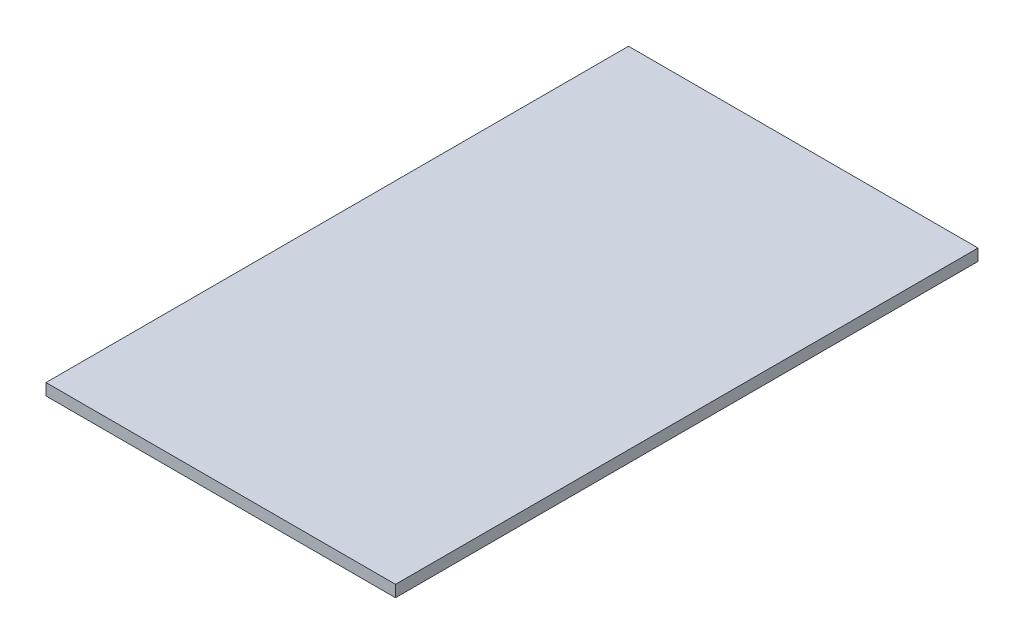
from build123d import *

# Parameters (mm, degrees)
SKETCH1_W           = 60
SKETCH1_H           = 100
BOSS_EXTRUDE1_DEPTH = 2


with BuildPart() as part:
    # Sketch1 → Boss-Extrude1 (new body)
    with BuildSketch(Plane(origin=(0, 0, 0), x_dir=(1, 0, 0), z_dir=(0, 1, 0))):
        Rectangle(SKETCH1_W, SKETCH1_H)
    extrude(amount=BOSS_EXTRUDE1_DEPTH)


solid = part.part
